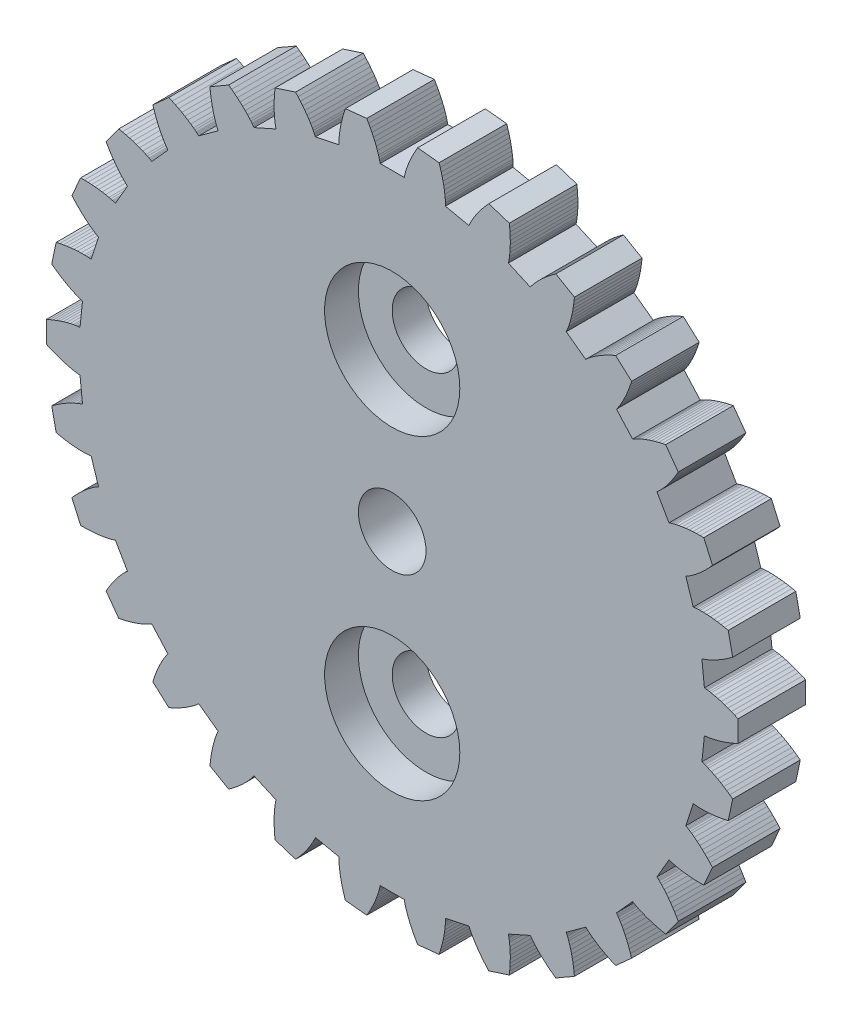
from build123d import *

# Parameters (mm, degrees)
MODEL_R             = 1.5
BOSS_EXTRUDE1_DEPTH = 3
SKETCH1_R           = 3
CUT_EXTRUDE1_DEPTH  = 1.5
SKETCH2_R           = 1.5
CUT_EXTRUDE2_DEPTH  = 1.5


with BuildPart() as part:
    # Model → Boss-Extrude1 (new body)
    with BuildSketch(Plane.XY):
        Polygon((29.209, 16.2732), (29.246, 16.2699), (29.2831, 16.266), (29.3202, 16.2615), (29.3573, 16.2565), (29.4317, 16.245), (29.5061, 16.2317), (29.6552, 16.2001), (29.8045, 16.1625), (29.954, 16.1194), (30.1035, 16.0712), (30.2531, 16.0181), (30.4025, 15.9603), (30.5519, 15.8981), (30.7012, 15.8315), (30.7012, 14.8771), (30.5519, 14.8105), (30.4025, 14.7482), (30.2531, 14.6905), (30.1035, 14.6374), (29.954, 14.5891), (29.8045, 14.5461), (29.6552, 14.5085), (29.5061, 14.4769), (29.4317, 14.4636), (29.3573, 14.4521), (29.3202, 14.4471), (29.2831, 14.4426), (29.246, 14.4387), (29.209, 14.4354), (29.0973, 13.3725), (29.1328, 13.3616), (29.1683, 13.3501), (29.2036, 13.338), (29.2389, 13.3254), (29.3092, 13.2987), (29.3793, 13.2702), (29.5185, 13.2083), (29.6568, 13.1405), (29.794, 13.0673), (29.9303, 12.989), (30.0655, 12.906), (30.1997, 12.8184), (30.3329, 12.7264), (30.465, 12.6303), (30.2666, 11.6967), (30.1068, 11.6626), (29.9477, 11.6328), (29.7895, 11.6074), (29.6321, 11.5865), (29.4759, 11.5704), (29.3207, 11.5594), (29.1668, 11.5536), (29.0144, 11.5537), (28.9389, 11.5562), (28.8637, 11.5604), (28.8264, 11.5632), (28.7892, 11.5666), (28.7521, 11.5704), (28.7152, 11.5749), (28.3849, 10.5585), (28.4174, 10.5404), (28.4497, 10.5218), (28.4818, 10.5026), (28.5137, 10.4829), (28.5769, 10.4422), (28.6395, 10.3998), (28.7628, 10.3103), (28.884, 10.2152), (29.003, 10.115), (29.12, 10.0102), (29.235, 9.9008), (29.3481, 9.7873), (29.4592, 9.6696), (29.5684, 9.5481), (29.1802, 8.6762), (29.0168, 8.6761), (28.8551, 8.68), (28.695, 8.688), (28.5368, 8.7003), (28.3806, 8.7171), (28.2265, 8.7385), (28.0748, 8.7649), (27.9257, 8.7967), (27.8523, 8.8148), (27.7797, 8.8345), (27.7438, 8.8451), (27.7081, 8.8561), (27.6726, 8.8676), (27.6375, 8.8796), (27.1031, 7.9541), (27.1311, 7.9296), (27.1588, 7.9047), (27.1862, 7.8793), (27.2133, 7.8534), (27.2667, 7.8004), (27.3191, 7.7459), (27.4211, 7.6327), (27.5198, 7.5145), (27.6154, 7.3918), (27.708, 7.2649), (27.7978, 7.134), (27.8848, 6.9994), (27.9691, 6.8613), (28.0507, 6.7197), (27.4897, 5.9476), (27.3298, 5.9814), (27.1724, 6.0188), (27.0175, 6.06), (26.8653, 6.1049), (26.7159, 6.1538), (26.5697, 6.2068), (26.4268, 6.2641), (26.2876, 6.3262), (26.2196, 6.3592), (26.1527, 6.3936), (26.1197, 6.4114), (26.0871, 6.4296), (26.0548, 6.4482), (26.0229, 6.4673), (25.3078, 5.6731), (25.3301, 5.6433), (25.352, 5.6132), (25.3735, 5.5826), (25.3946, 5.5517), (25.4358, 5.4888), (25.4757, 5.4245), (25.552, 5.2926), (25.624, 5.1565), (25.692, 5.0166), (25.7562, 4.8732), (25.8168, 4.7265), (25.8739, 4.5768), (25.9276, 4.4241), (25.978, 4.2687), (25.2687, 3.63), (25.1194, 3.6964), (24.9732, 3.7657), (24.8302, 3.8382), (24.6907, 3.9138), (24.5548, 3.9926), (24.4227, 4.0749), (24.2949, 4.1607), (24.1717, 4.2503), (24.112, 4.2968), (24.0537, 4.3443), (24.0251, 4.3685), (23.997, 4.3931), (23.9693, 4.4181), (23.9421, 4.4434), (23.0774, 3.8152), (23.0931, 3.7815), (23.1082, 3.7474), (23.1229, 3.7131), (23.1371, 3.6784), (23.1644, 3.6083), (23.19, 3.5372), (23.2372, 3.3922), (23.2793, 3.2441), (23.3168, 3.0932), (23.3498, 2.9395), (23.3785, 2.7835), (23.4033, 2.6251), (23.4241, 2.4646), (23.441, 2.3021), (22.6144, 1.8249), (22.4822, 1.9208), (22.3536, 2.0191), (22.2288, 2.1197), (22.108, 2.2226), (21.9915, 2.328), (21.8795, 2.4359), (21.7722, 2.5464), (21.6703, 2.6598), (21.6216, 2.7176), (21.5745, 2.7762), (21.5516, 2.8058), (21.5292, 2.8357), (21.5072, 2.8659), (21.4859, 2.8963), (20.5095, 2.4616), (20.5178, 2.4254), (20.5256, 2.3889), (20.5328, 2.3523), (20.5395, 2.3154), (20.5516, 2.2411), (20.5619, 2.1662), (20.5779, 2.0147), (20.5883, 1.8611), (20.5935, 1.7056), (20.5939, 1.5485), (20.5896, 1.3898), (20.5808, 1.2298), (20.5678, 1.0685), (20.5506, 0.906), (19.6429, 0.6111), (19.5334, 0.7324), (19.4281, 0.8553), (19.3269, 0.9796), (19.2302, 1.1054), (19.1381, 1.2327), (19.051, 1.3615), (18.9691, 1.4919), (18.893, 1.624), (18.8573, 1.6907), (18.8234, 1.7578), (18.8072, 1.7916), (18.7915, 1.8255), (18.7763, 1.8595), (18.7617, 1.8937), (17.7163, 1.6715), (17.7169, 1.6343), (17.7169, 1.5971), (17.7164, 1.5597), (17.7153, 1.5223), (17.7116, 1.4471), (17.7061, 1.3717), (17.6903, 1.2201), (17.6685, 1.0677), (17.6413, 0.9146), (17.609, 0.7608), (17.5718, 0.6065), (17.53, 0.4518), (17.4837, 0.2967), (17.4331, 0.1414), (16.4839, 0.0416), (16.402, 0.183), (16.3245, 0.3251), (16.2515, 0.4677), (16.183, 0.6109), (16.1194, 0.7546), (16.0609, 0.8987), (16.008, 1.0433), (15.961, 1.1883), (15.9399, 1.2609), (15.9207, 1.3336), (15.9119, 1.3701), (15.9036, 1.4065), (15.8958, 1.4429), (15.8887, 1.4794), (14.8199, 1.4794), (14.8128, 1.4429), (14.805, 1.4065), (14.7967, 1.3701), (14.7878, 1.3336), (14.7686, 1.2609), (14.7476, 1.1883), (14.7006, 1.0433), (14.6476, 0.8987), (14.5891, 0.7546), (14.5256, 0.6109), (14.4571, 0.4677), (14.384, 0.3251), (14.3065, 0.183), (14.2247, 0.0416), (13.2755, 0.1414), (13.2249, 0.2967), (13.1786, 0.4518), (13.1368, 0.6065), (13.0996, 0.7608), (13.0673, 0.9146), (13.04, 1.0677), (13.0183, 1.2201), (13.0024, 1.3717), (12.997, 1.4471), (12.9933, 1.5223), (12.9922, 1.5597), (12.9916, 1.5971), (12.9916, 1.6343), (12.9922, 1.6715), (11.9468, 1.8937), (11.9323, 1.8595), (11.9171, 1.8255), (11.9014, 1.7916), (11.8852, 1.7578), (11.8513, 1.6907), (11.8156, 1.624), (11.7395, 1.4919), (11.6576, 1.3615), (11.5704, 1.2327), (11.4783, 1.1054), (11.3816, 0.9796), (11.2805, 0.8553), (11.1751, 0.7324), (11.0657, 0.6111), (10.158, 0.906), (10.1408, 1.0685), (10.1277, 1.2298), (10.119, 1.3898), (10.1147, 1.5485), (10.115, 1.7056), (10.1203, 1.8611), (10.1306, 2.0147), (10.1467, 2.1662), (10.157, 2.2411), (10.1691, 2.3154), (10.1758, 2.3523), (10.183, 2.3889), (10.1907, 2.4254), (10.199, 2.4616), (9.2227, 2.8963), (9.2013, 2.8659), (9.1794, 2.8357), (9.157, 2.8058), (9.1341, 2.7762), (9.087, 2.7176), (9.0382, 2.6598), (8.9363, 2.5464), (8.8291, 2.4359), (8.7171, 2.328), (8.6005, 2.2226), (8.4798, 2.1197), (8.355, 2.0191), (8.2264, 1.9208), (8.0941, 1.8249), (7.2676, 2.3021), (7.2845, 2.4646), (7.3053, 2.6251), (7.33, 2.7835), (7.3588, 2.9395), (7.3918, 3.0932), (7.4292, 3.2441), (7.4713, 3.3922), (7.5185, 3.5372), (7.5442, 3.6083), (7.5714, 3.6784), (7.5857, 3.7131), (7.6003, 3.7474), (7.6155, 3.7815), (7.6312, 3.8152), (6.7665, 4.4434), (6.7393, 4.4181), (6.7116, 4.3931), (6.6835, 4.3685), (6.6549, 4.3443), (6.5966, 4.2968), (6.5369, 4.2503), (6.4137, 4.1607), (6.2858, 4.0749), (6.1538, 3.9926), (6.0179, 3.9138), (5.8784, 3.8382), (5.7354, 3.7657), (5.5892, 3.6964), (5.4399, 3.63), (4.7306, 4.2687), (4.7809, 4.4241), (4.8346, 4.5768), (4.8918, 4.7265), (4.9524, 4.8732), (5.0166, 5.0166), (5.0846, 5.1565), (5.1565, 5.2926), (5.2328, 5.4245), (5.2728, 5.4888), (5.314, 5.5517), (5.3351, 5.5826), (5.3566, 5.6132), (5.3785, 5.6433), (5.4008, 5.6731), (4.6857, 6.4673), (4.6538, 6.4482), (4.6215, 6.4296), (4.5889, 6.4114), (4.5559, 6.3936), (4.489, 6.3592), (4.4209, 6.3262), (4.2818, 6.2641), (4.1389, 6.2068), (3.9926, 6.1538), (3.8433, 6.1049), (3.6911, 6.06), (3.5362, 6.0188), (3.3788, 5.9814), (3.2189, 5.9476), (2.6579, 6.7197), (2.7395, 6.8613), (2.8238, 6.9994), (2.9108, 7.134), (3.0005, 7.2649), (3.0932, 7.3918), (3.1887, 7.5145), (3.2875, 7.6327), (3.3895, 7.7459), (3.4419, 7.8004), (3.4953, 7.8534), (3.5224, 7.8793), (3.5498, 7.9047), (3.5775, 7.9296), (3.6055, 7.9541), (3.0711, 8.8796), (3.0359, 8.8676), (3.0005, 8.8561), (2.9648, 8.8451), (2.9288, 8.8345), (2.8562, 8.8148), (2.7828, 8.7967), (2.6338, 8.7649), (2.4821, 8.7385), (2.328, 8.7171), (2.1718, 8.7003), (2.0136, 8.688), (1.8535, 8.68), (1.6917, 8.6761), (1.5283, 8.6762), (1.1401, 9.5481), (1.2494, 9.6696), (1.3605, 9.7873), (1.4736, 9.9008), (1.5886, 10.0102), (1.7056, 10.115), (1.8246, 10.2152), (1.9457, 10.3103), (2.0691, 10.3998), (2.1317, 10.4422), (2.1949, 10.4829), (2.2268, 10.5026), (2.2589, 10.5218), (2.2911, 10.5404), (2.3236, 10.5585), (1.9934, 11.5749), (1.9565, 11.5704), (1.9194, 11.5666), (1.8822, 11.5632), (1.8448, 11.5604), (1.7697, 11.5562), (1.6941, 11.5537), (1.5417, 11.5536), (1.3879, 11.5594), (1.2327, 11.5704), (1.0764, 11.5865), (0.9191, 11.6074), (0.7609, 11.6328), (0.6018, 11.6626), (0.442, 11.6967), (0.2436, 12.6303), (0.3757, 12.7264), (0.5089, 12.8184), (0.6431, 12.906), (0.7783, 12.989), (0.9146, 13.0673), (1.0518, 13.1405), (1.19, 13.2083), (1.3293, 13.2702), (1.3993, 13.2987), (1.4697, 13.3254), (1.5049, 13.338), (1.5403, 13.3501), (1.5757, 13.3616), (1.6113, 13.3725), (1.4996, 14.4354), (1.4625, 14.4387), (1.4255, 14.4426), (1.3884, 14.4471), (1.3512, 14.4521), (1.2769, 14.4636), (1.2025, 14.4769), (1.0534, 14.5085), (0.9041, 14.5461), (0.7546, 14.5891), (0.6051, 14.6374), (0.4555, 14.6905), (0.306, 14.7482), (0.1566, 14.8105), (0.0074, 14.8771), (0.0074, 15.8315), (0.1566, 15.8981), (0.306, 15.9603), (0.4555, 16.0181), (0.6051, 16.0712), (0.7546, 16.1194), (0.9041, 16.1625), (1.0534, 16.2001), (1.2025, 16.2317), (1.2769, 16.245), (1.3512, 16.2565), (1.3884, 16.2615), (1.4255, 16.266), (1.4625, 16.2699), (1.4996, 16.2732), (1.6113, 17.3361), (1.5757, 17.347), (1.5403, 17.3585), (1.5049, 17.3706), (1.4697, 17.3832), (1.3993, 17.4099), (1.3293, 17.4384), (1.19, 17.5003), (1.0518, 17.5681), (0.9146, 17.6413), (0.7783, 17.7196), (0.6431, 17.8026), (0.5089, 17.8902), (0.3757, 17.9821), (0.2436, 18.0783), (0.442, 19.0119), (0.6018, 19.046), (0.7609, 19.0758), (0.9191, 19.1012), (1.0764, 19.1221), (1.2327, 19.1381), (1.3879, 19.1492), (1.5417, 19.1549), (1.6941, 19.1548), (1.7697, 19.1524), (1.8448, 19.1482), (1.8822, 19.1453), (1.9194, 19.142), (1.9565, 19.1381), (1.9934, 19.1336), (2.3236, 20.1501), (2.2911, 20.1681), (2.2589, 20.1868), (2.2268, 20.206), (2.1949, 20.2256), (2.1317, 20.2664), (2.0691, 20.3088), (1.9457, 20.3983), (1.8246, 20.4934), (1.7056, 20.5935), (1.5886, 20.6984), (1.4736, 20.8077), (1.3605, 20.9213), (1.2494, 21.0389), (1.1401, 21.1605), (1.5283, 22.0324), (1.6917, 22.0325), (1.8535, 22.0286), (2.0136, 22.0206), (2.1718, 22.0083), (2.328, 21.9915), (2.4821, 21.9701), (2.6338, 21.9437), (2.7828, 21.9119), (2.8562, 21.8938), (2.9288, 21.874), (2.9648, 21.8635), (3.0005, 21.8525), (3.0359, 21.841), (3.0711, 21.8289), (3.6055, 22.7545), (3.5775, 22.7789), (3.5498, 22.8039), (3.5224, 22.8293), (3.4953, 22.8552), (3.4419, 22.9082), (3.3895, 22.9627), (3.2875, 23.0759), (3.1887, 23.194), (3.0932, 23.3168), (3.0005, 23.4437), (2.9108, 23.5745), (2.8238, 23.7091), (2.7395, 23.8473), (2.6579, 23.9889), (3.2189, 24.761), (3.3788, 24.7272), (3.5362, 24.6897), (3.6911, 24.6486), (3.8433, 24.6037), (3.9926, 24.5548), (4.1389, 24.5018), (4.2818, 24.4444), (4.4209, 24.3823), (4.489, 24.3494), (4.5559, 24.315), (4.5889, 24.2972), (4.6215, 24.279), (4.6538, 24.2604), (4.6857, 24.2413), (5.4008, 25.0355), (5.3785, 25.0652), (5.3566, 25.0954), (5.3351, 25.1259), (5.314, 25.1569), (5.2728, 25.2198), (5.2328, 25.284), (5.1565, 25.416), (5.0846, 25.5521), (5.0166, 25.692), (4.9524, 25.8354), (4.8918, 25.9821), (4.8346, 26.1318), (4.7809, 26.2845), (4.7306, 26.4399), (5.4399, 27.0785), (5.5892, 27.0122), (5.7354, 26.9429), (5.8784, 26.8704), (6.0179, 26.7948), (6.1538, 26.7159), (6.2858, 26.6337), (6.4137, 26.5479), (6.5369, 26.4582), (6.5966, 26.4118), (6.6549, 26.3643), (6.6835, 26.34), (6.7116, 26.3154), (6.7393, 26.2905), (6.7665, 26.2652), (7.6312, 26.8934), (7.6155, 26.9271), (7.6003, 26.9612), (7.5857, 26.9955), (7.5714, 27.0302), (7.5442, 27.1003), (7.5185, 27.1714), (7.4713, 27.3163), (7.4292, 27.4644), (7.3918, 27.6154), (7.3588, 27.769), (7.33, 27.9251), (7.3053, 28.0834), (7.2845, 28.2439), (7.2676, 28.4065), (8.0941, 28.8837), (8.2264, 28.7877), (8.355, 28.6895), (8.4798, 28.5889), (8.6005, 28.4859), (8.7171, 28.3806), (8.8291, 28.2727), (8.9363, 28.1621), (9.0382, 28.0488), (9.087, 27.991), (9.1341, 27.9324), (9.157, 27.9027), (9.1794, 27.8728), (9.2013, 27.8427), (9.2227, 27.8123), (10.199, 28.247), (10.1907, 28.2832), (10.183, 28.3196), (10.1758, 28.3563), (10.1691, 28.3932), (10.157, 28.4674), (10.1467, 28.5423), (10.1306, 28.6939), (10.1203, 28.8475), (10.115, 29.003), (10.1147, 29.1601), (10.119, 29.3187), (10.1277, 29.4788), (10.1408, 29.6401), (10.158, 29.8026), (11.0657, 30.0975), (11.1751, 29.9762), (11.2805, 29.8533), (11.3816, 29.729), (11.4783, 29.6032), (11.5704, 29.4759), (11.6576, 29.347), (11.7395, 29.2166), (11.8156, 29.0846), (11.8513, 29.0179), (11.8852, 28.9508), (11.9014, 28.917), (11.9171, 28.8831), (11.9323, 28.8491), (11.9468, 28.8149), (12.9922, 29.0371), (12.9916, 29.0742), (12.9916, 29.1115), (12.9922, 29.1489), (12.9933, 29.1863), (12.997, 29.2614), (13.0024, 29.3369), (13.0183, 29.4884), (13.04, 29.6409), (13.0673, 29.794), (13.0996, 29.9478), (13.1368, 30.1021), (13.1786, 30.2568), (13.2249, 30.4118), (13.2755, 30.5672), (14.2247, 30.667), (14.3065, 30.5255), (14.384, 30.3835), (14.4571, 30.2408), (14.5256, 30.0976), (14.5891, 29.954), (14.6476, 29.8098), (14.7006, 29.6653), (14.7476, 29.5203), (14.7686, 29.4477), (14.7878, 29.3749), (14.7967, 29.3385), (14.805, 29.3021), (14.8128, 29.2656), (14.8199, 29.2292), (15.8887, 29.2292), (15.8958, 29.2656), (15.9036, 29.3021), (15.9119, 29.3385), (15.9207, 29.3749), (15.9399, 29.4477), (15.961, 29.5203), (16.008, 29.6653), (16.0609, 29.8098), (16.1194, 29.954), (16.183, 30.0976), (16.2515, 30.2408), (16.3245, 30.3835), (16.402, 30.5255), (16.4839, 30.667), (17.4331, 30.5672), (17.4837, 30.4118), (17.53, 30.2568), (17.5718, 30.1021), (17.609, 29.9478), (17.6413, 29.794), (17.6685, 29.6409), (17.6903, 29.4884), (17.7061, 29.3369), (17.7116, 29.2614), (17.7153, 29.1863), (17.7164, 29.1489), (17.7169, 29.1115), (17.7169, 29.0742), (17.7163, 29.0371), (18.7617, 28.8149), (18.7763, 28.8491), (18.7915, 28.8831), (18.8072, 28.917), (18.8234, 28.9508), (18.8573, 29.0179), (18.893, 29.0846), (18.9691, 29.2166), (19.051, 29.347), (19.1381, 29.4759), (19.2302, 29.6032), (19.3269, 29.729), (19.4281, 29.8533), (19.5334, 29.9762), (19.6429, 30.0975), (20.5506, 29.8026), (20.5678, 29.6401), (20.5808, 29.4788), (20.5896, 29.3187), (20.5939, 29.1601), (20.5935, 29.003), (20.5883, 28.8475), (20.5779, 28.6939), (20.5619, 28.5423), (20.5516, 28.4674), (20.5395, 28.3932), (20.5328, 28.3563), (20.5256, 28.3196), (20.5178, 28.2832), (20.5095, 28.247), (21.4859, 27.8123), (21.5072, 27.8427), (21.5292, 27.8728), (21.5516, 27.9027), (21.5745, 27.9324), (21.6216, 27.991), (21.6703, 28.0488), (21.7722, 28.1621), (21.8795, 28.2727), (21.9915, 28.3806), (22.108, 28.4859), (22.2288, 28.5889), (22.3536, 28.6895), (22.4822, 28.7877), (22.6144, 28.8837), (23.441, 28.4065), (23.4241, 28.2439), (23.4033, 28.0834), (23.3785, 27.9251), (23.3498, 27.769), (23.3168, 27.6154), (23.2793, 27.4644), (23.2372, 27.3163), (23.19, 27.1714), (23.1644, 27.1003), (23.1371, 27.0302), (23.1229, 26.9955), (23.1082, 26.9612), (23.0931, 26.9271), (23.0774, 26.8934), (23.9421, 26.2652), (23.9693, 26.2905), (23.997, 26.3154), (24.0251, 26.34), (24.0537, 26.3643), (24.112, 26.4118), (24.1717, 26.4582), (24.2949, 26.5479), (24.4227, 26.6337), (24.5548, 26.7159), (24.6907, 26.7948), (24.8302, 26.8704), (24.9732, 26.9429), (25.1194, 27.0122), (25.2687, 27.0785), (25.978, 26.4399), (25.9276, 26.2845), (25.8739, 26.1318), (25.8168, 25.9821), (25.7562, 25.8354), (25.692, 25.692), (25.624, 25.5521), (25.552, 25.416), (25.4757, 25.284), (25.4358, 25.2198), (25.3946, 25.1569), (25.3735, 25.1259), (25.352, 25.0954), (25.3301, 25.0652), (25.3078, 25.0355), (26.0229, 24.2413), (26.0548, 24.2604), (26.0871, 24.279), (26.1197, 24.2972), (26.1527, 24.315), (26.2196, 24.3494), (26.2876, 24.3823), (26.4268, 24.4444), (26.5697, 24.5018), (26.7159, 24.5548), (26.8653, 24.6037), (27.0175, 24.6486), (27.1724, 24.6897), (27.3298, 24.7272), (27.4897, 24.761), (28.0507, 23.9889), (27.9691, 23.8473), (27.8848, 23.7091), (27.7978, 23.5745), (27.708, 23.4437), (27.6154, 23.3168), (27.5198, 23.194), (27.4211, 23.0759), (27.3191, 22.9627), (27.2667, 22.9082), (27.2133, 22.8552), (27.1862, 22.8293), (27.1588, 22.8039), (27.1311, 22.7789), (27.1031, 22.7545), (27.6375, 21.8289), (27.6726, 21.841), (27.7081, 21.8525), (27.7438, 21.8635), (27.7797, 21.874), (27.8523, 21.8938), (27.9257, 21.9119), (28.0748, 21.9437), (28.2265, 21.9701), (28.3806, 21.9915), (28.5368, 22.0083), (28.695, 22.0206), (28.8551, 22.0286), (29.0168, 22.0325), (29.1802, 22.0324), (29.5684, 21.1605), (29.4592, 21.0389), (29.3481, 20.9213), (29.235, 20.8077), (29.12, 20.6984), (29.003, 20.5935), (28.884, 20.4934), (28.7628, 20.3983), (28.6395, 20.3088), (28.5769, 20.2664), (28.5137, 20.2256), (28.4818, 20.206), (28.4497, 20.1868), (28.4174, 20.1681), (28.3849, 20.1501), (28.7152, 19.1336), (28.7521, 19.1381), (28.7892, 19.142), (28.8264, 19.1453), (28.8637, 19.1482), (28.9389, 19.1524), (29.0144, 19.1548), (29.1668, 19.1549), (29.3207, 19.1492), (29.4759, 19.1381), (29.6321, 19.1221), (29.7895, 19.1012), (29.9477, 19.0758), (30.1068, 19.046), (30.2666, 19.0119), (30.465, 18.0783), (30.3329, 17.9821), (30.1997, 17.8902), (30.0655, 17.8026), (29.9303, 17.7196), (29.794, 17.6413), (29.6568, 17.5681), (29.5185, 17.5003), (29.3793, 17.4384), (29.3092, 17.4099), (29.2389, 17.3832), (29.2036, 17.3706), (29.1683, 17.3585), (29.1328, 17.347), (29.0973, 17.3361), align=None)
        with Locations((15.3543, 15.3543)):
            Circle(MODEL_R, mode=Mode.SUBTRACT)
    extrude(amount=BOSS_EXTRUDE1_DEPTH)

    # Sketch1 → Cut-Extrude1 (cut)
    with BuildSketch(Plane.XY.offset(3)):
        with Locations((15.3543, 22.3543)):
            Circle(SKETCH1_R)
        with Locations((15.3543, 8.3543)):
            Circle(SKETCH1_R)
    extrude(amount=-CUT_EXTRUDE1_DEPTH, mode=Mode.SUBTRACT)

    # Sketch2 → Cut-Extrude2 (cut)
    with BuildSketch(Plane.XY.offset(1.5)):
        with Locations((15.3543, 22.3543)):
            Circle(SKETCH2_R)
        with Locations((15.3543, 8.3543)):
            Circle(SKETCH2_R)
    extrude(amount=-CUT_EXTRUDE2_DEPTH, mode=Mode.SUBTRACT)


solid = part.part
